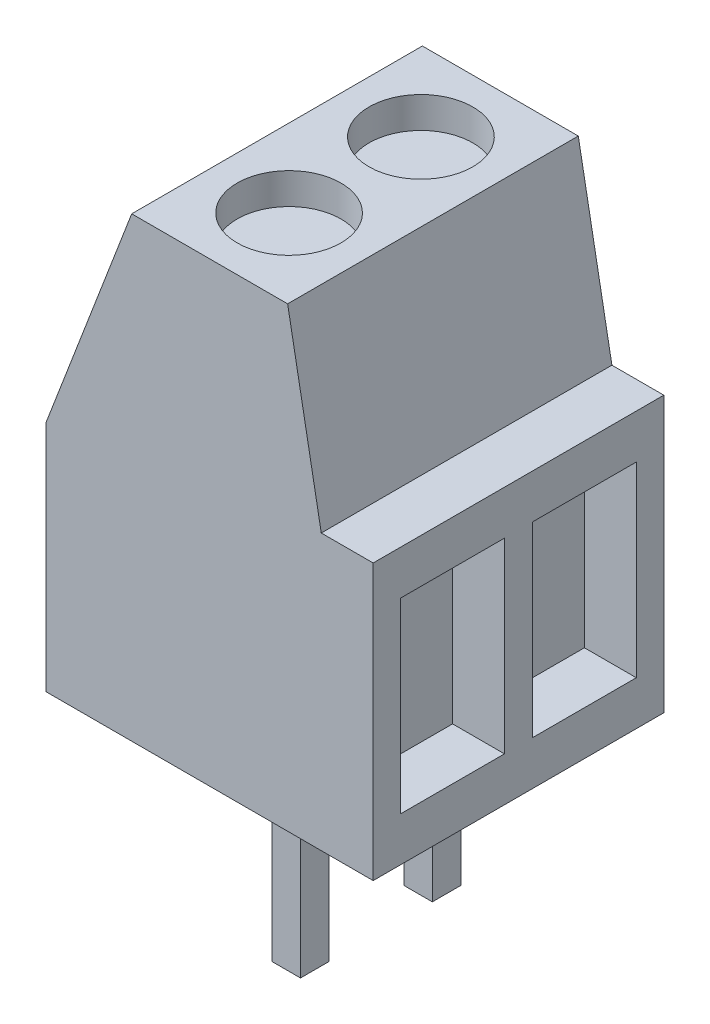
from build123d import *

# Parameters (mm, degrees)
BOSS_EXTRUDE1_DEPTH   = 5.6
SKETCH3_R             = 1
CUT_EXTRUDE1_DEPTH    = 0.6
SKETCH4_W             = 2
SKETCH4_H             = 3.6
CUT_EXTRUDE2_DEPTH    = 1
SKETCH5_W             = 0.55
SKETCH5_H             = 0.55
BOSS_EXTRUDE2_DEPTH   = 3.8
BOSS_EXTRUDE2_2_DEPTH = 3.8


with BuildPart() as part:
    # Sketch2 → Boss-Extrude1 (new body)
    with BuildSketch(Plane.XY):
        Polygon((6.3, 5.3), (5.3, 5.3), (4.652088092, 8.8), (1.647911908, 8.8), (0, 4.5), (0, 0), (6.3, 0), align=None)
    extrude(amount=-BOSS_EXTRUDE1_DEPTH)

    # Sketch3 → Cut-Extrude1 (cut)
    with BuildSketch(Plane(origin=(0, 8.8, 0), x_dir=(1, 0, 0), z_dir=(0, 1, 0))):
        with Locations((3.15, 1.53)):
            Circle(SKETCH3_R)
        with Locations((3.15, 4.07)):
            Circle(SKETCH3_R)
    extrude(amount=-CUT_EXTRUDE1_DEPTH, mode=Mode.SUBTRACT)

    # Sketch4 → Cut-Extrude2 (cut)
    with BuildSketch(Plane(origin=(6.3, 0, 0), x_dir=(0, 0, -1), z_dir=(1, 0, 0))):
        with Locations((4.07, 2.65)):
            Rectangle(SKETCH4_W, SKETCH4_H)
        with Locations((1.53, 2.65)):
            Rectangle(SKETCH4_W, SKETCH4_H)
    extrude(amount=-CUT_EXTRUDE2_DEPTH, mode=Mode.SUBTRACT)


with BuildPart() as body_2:
    # Sketch5 → Boss-Extrude2 (new body)
    with BuildSketch(Plane.XZ):
        with Locations((3.15, -1.75)):
            Rectangle(SKETCH5_W, SKETCH5_H)
    extrude(amount=BOSS_EXTRUDE2_DEPTH)


with BuildPart() as body_3:
    # Sketch5 → Boss-Extrude2 2 (new body)
    with BuildSketch(Plane.XZ):
        with Locations((3.15, -4.29)):
            Rectangle(SKETCH5_W, SKETCH5_H)
    extrude(amount=BOSS_EXTRUDE2_2_DEPTH)


solid = Compound([part.part, body_2.part, body_3.part])
